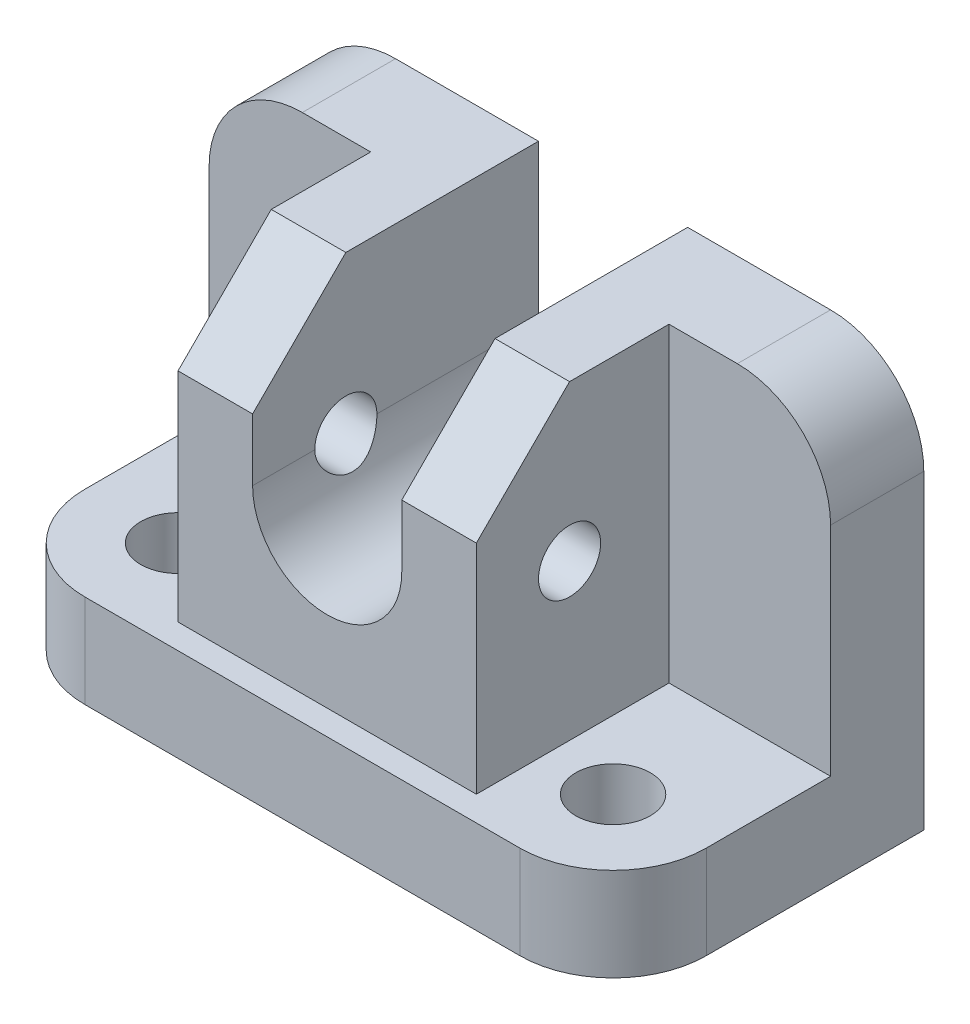
from build123d import *

# Parameters (mm, degrees)
SKETCH1_W           = 100
SKETCH1_H           = 50
BOSS_EXTRUDE1_DEPTH = 15
SKETCH2_W           = 100
SKETCH2_H           = 65
BOSS_EXTRUDE2_DEPTH = 46
CUT_EXTRUDE1_DEPTH  = 47
CUT_EXTRUDE2_DEPTH  = 39
CUT_EXTRUDE3_DEPTH  = 26
FILLET1_R           = 15
SKETCH6_R           = 5
CUT_EXTRUDE4_DEPTH  = 75
SKETCH7_R           = 6
CUT_EXTRUDE5_DEPTH  = 26


with BuildPart() as part:
    # Sketch1 → Boss-Extrude1 (new body)
    with BuildSketch(Plane(origin=(0, 0, 0), x_dir=(1, 0, 0), z_dir=(0, 1, 0))):
        with Locations((0, -25)):
            Rectangle(SKETCH1_W, SKETCH1_H)
    extrude(amount=BOSS_EXTRUDE1_DEPTH)

    # Sketch2 → Boss-Extrude2 (add)
    with BuildSketch(Plane.XY):
        with Locations((0, 32.5)):
            Rectangle(SKETCH2_W, SKETCH2_H)
    extrude(amount=BOSS_EXTRUDE2_DEPTH)

    # Sketch3 → Cut-Extrude1 (cut, through all)
    with BuildSketch(Plane.XY.offset(46)):
        with BuildLine():
            Line((-12, 65), (-12, 40))
            ThreePointArc((-12, 40), (-8.485281374, 31.514718626), (0, 28))
            ThreePointArc((0, 28), (8.485281374, 31.514718626), (12, 40))
            Line((12, 40), (12, 65))
            Line((12, 65), (-12, 65))
        make_face()
    extrude(amount=-CUT_EXTRUDE1_DEPTH, mode=Mode.SUBTRACT)

    # Sketch4 → Cut-Extrude2 (cut, through all)
    with BuildSketch(Plane(origin=(-12, 0, 0), x_dir=(0, 0, -1), z_dir=(1, 0, 0))):
        Polygon((-31, 65), (-46, 50), (-46, 65), align=None)
    cut_extrude2 = extrude(amount=-CUT_EXTRUDE2_DEPTH, mode=Mode.SUBTRACT)

    # Mirror1: Cut-Extrude2 across plane
    add(cut_extrude2.mirror(Plane(origin=(0, 0, 0), x_dir=(0, 0, 1), z_dir=(1, 0, 0))), mode=Mode.SUBTRACT)

    # Sketch5 → Cut-Extrude3 (cut)
    with BuildSketch(Plane.ZY.offset(50)):
        Polygon((15, 65), (15, 15), (46, 15), (46, 50), (31, 65), align=None)
    cut_extrude3 = extrude(amount=-CUT_EXTRUDE3_DEPTH, mode=Mode.SUBTRACT)

    # Mirror2: Cut-Extrude3 across plane
    add(cut_extrude3.mirror(Plane(origin=(0, 0, 0), x_dir=(0, 0, 1), z_dir=(1, 0, 0))), mode=Mode.SUBTRACT)

    # Fillet1
    fillet1_edges = [part.edges().sort_by_distance(p)[0] for p in [
        (-50, 65, 7.5),
        (50, 7.5, 50),
        (-50, 7.5, 50),
        (50, 65, 7.5),
    ]]
    fillet(fillet1_edges, radius=FILLET1_R)

    # Sketch6 → Cut-Extrude4 (cut, through all)
    with BuildSketch(Plane(origin=(24, 0, 0), x_dir=(0, 0, -1), z_dir=(1, 0, 0))):
        with Locations((-31, 40)):
            Circle(SKETCH6_R)
    extrude(amount=-CUT_EXTRUDE4_DEPTH, mode=Mode.SUBTRACT)

    # Sketch7 → Cut-Extrude5 (cut)
    with BuildSketch(Plane(origin=(0, 15, 0), x_dir=(1, 0, 0), z_dir=(0, 1, 0))):
        with Locations((-35, -35)):
            Circle(SKETCH7_R)
    cut_extrude5 = extrude(amount=-CUT_EXTRUDE5_DEPTH, mode=Mode.SUBTRACT)

    # Mirror3: Cut-Extrude5 across plane
    add(cut_extrude5.mirror(Plane(origin=(0, 0, 0), x_dir=(0, 0, 1), z_dir=(1, 0, 0))), mode=Mode.SUBTRACT)


solid = part.part
